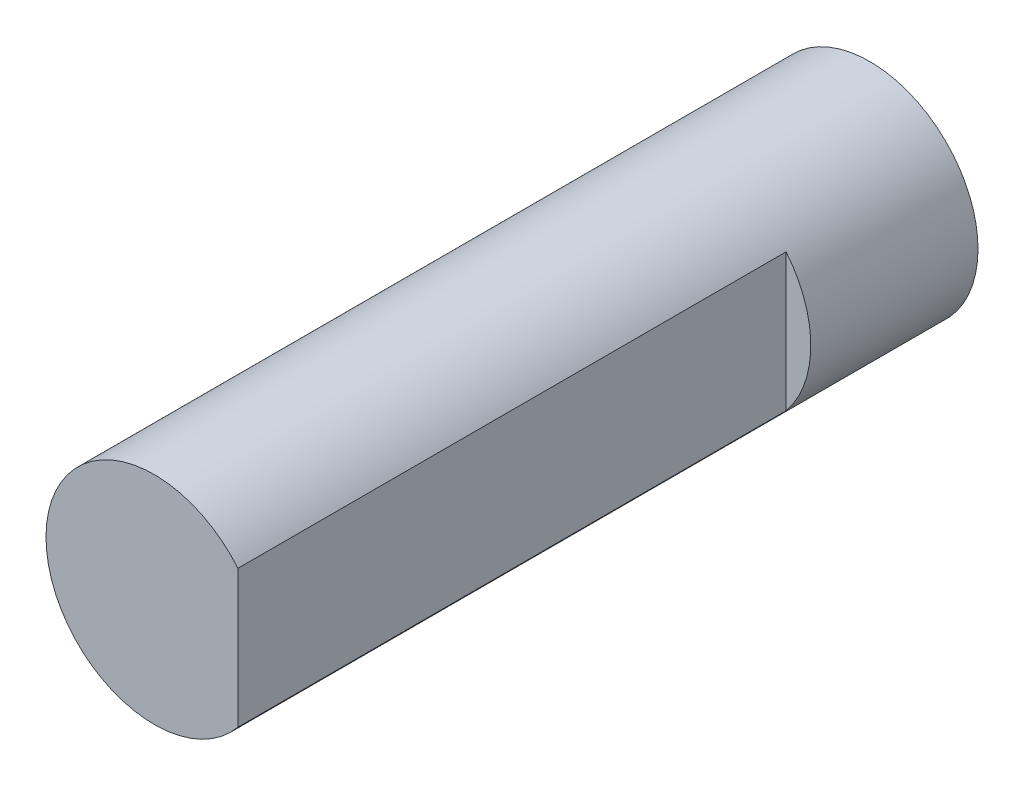
from build123d import *

# Parameters (mm, degrees)
SKETCH17_R          = 1.975
BOSS_EXTRUDE7_DEPTH = 13.05
CUT_EXTRUDE2_DEPTH  = 10


with BuildPart() as part:
    # Sketch17 → Boss-Extrude7 (new body)
    with BuildSketch(Plane.XY.offset(54.6)):
        Circle(SKETCH17_R)
    extrude(amount=BOSS_EXTRUDE7_DEPTH)

    # Sketch19 → Cut-Extrude2 (cut)
    with BuildSketch(Plane.XY.offset(67.65)):
        Polygon((1.525, 0), (1.525, 1.25499004), (2.661624003, 0.419060713), (2.35393594, -0.855047839), (1.525, -1.25499004), align=None)
    extrude(amount=-CUT_EXTRUDE2_DEPTH, mode=Mode.SUBTRACT)


solid = part.part
